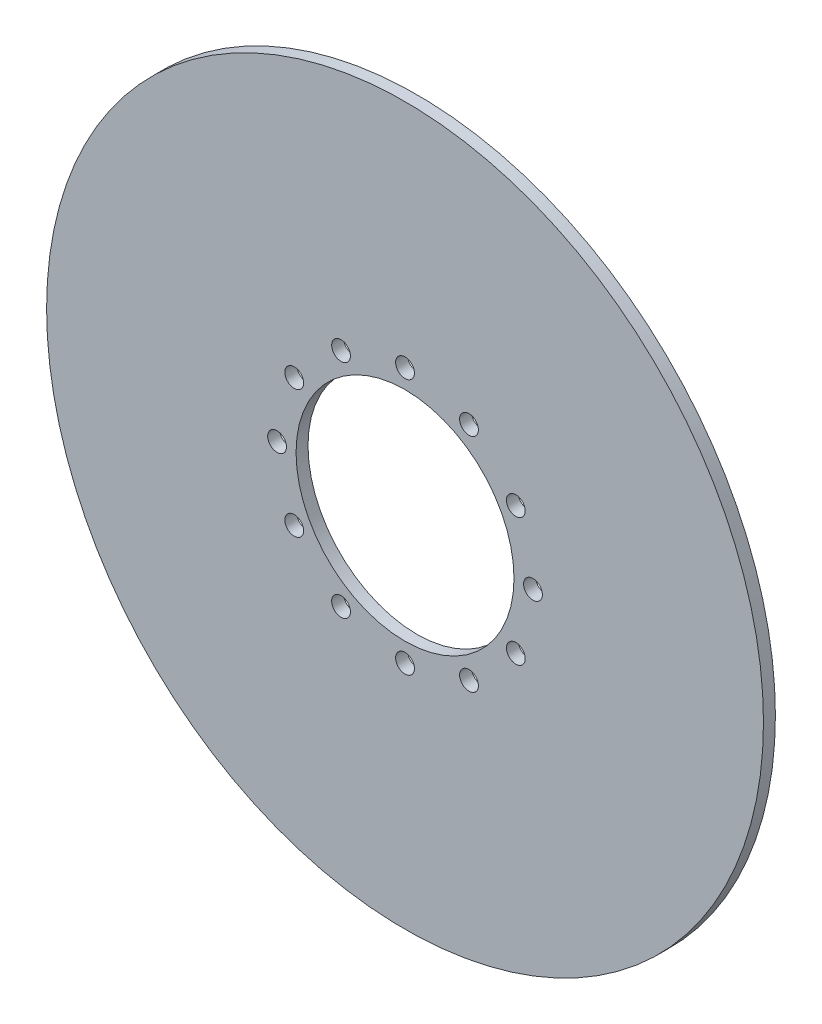
from build123d import *

# Parameters (mm, degrees)
SKETCH1_R           = 95.25
SKETCH1_R_2         = 28.956
SKETCH1_R_3         = 2.49698907
BOSS_EXTRUDE1_DEPTH = 3.175


with BuildPart() as part:
    # Sketch1 → Boss-Extrude1 (new body)
    with BuildSketch(Plane.XY):
        Circle(SKETCH1_R)
        Circle(SKETCH1_R_2, mode=Mode.SUBTRACT)
        with Locations((0, 34)):
            Circle(SKETCH1_R_3, mode=Mode.SUBTRACT)
        with Locations((17, 29.444863729)):
            Circle(SKETCH1_R_3, mode=Mode.SUBTRACT)
        with Locations((29.444863729, 17)):
            Circle(SKETCH1_R_3, mode=Mode.SUBTRACT)
        with Locations((34, 0)):
            Circle(SKETCH1_R_3, mode=Mode.SUBTRACT)
        with Locations((29.444863729, -17)):
            Circle(SKETCH1_R_3, mode=Mode.SUBTRACT)
        with Locations((17, -29.444863729)):
            Circle(SKETCH1_R_3, mode=Mode.SUBTRACT)
        with Locations((0, -34)):
            Circle(SKETCH1_R_3, mode=Mode.SUBTRACT)
        with Locations((-17, -29.444863729)):
            Circle(SKETCH1_R_3, mode=Mode.SUBTRACT)
        with Locations((-29.444863729, -17)):
            Circle(SKETCH1_R_3, mode=Mode.SUBTRACT)
        with Locations((-34, 0)):
            Circle(SKETCH1_R_3, mode=Mode.SUBTRACT)
        with Locations((-29.444863729, 17)):
            Circle(SKETCH1_R_3, mode=Mode.SUBTRACT)
        with Locations((-17, 29.444863729)):
            Circle(SKETCH1_R_3, mode=Mode.SUBTRACT)
    extrude(amount=BOSS_EXTRUDE1_DEPTH)


solid = part.part
